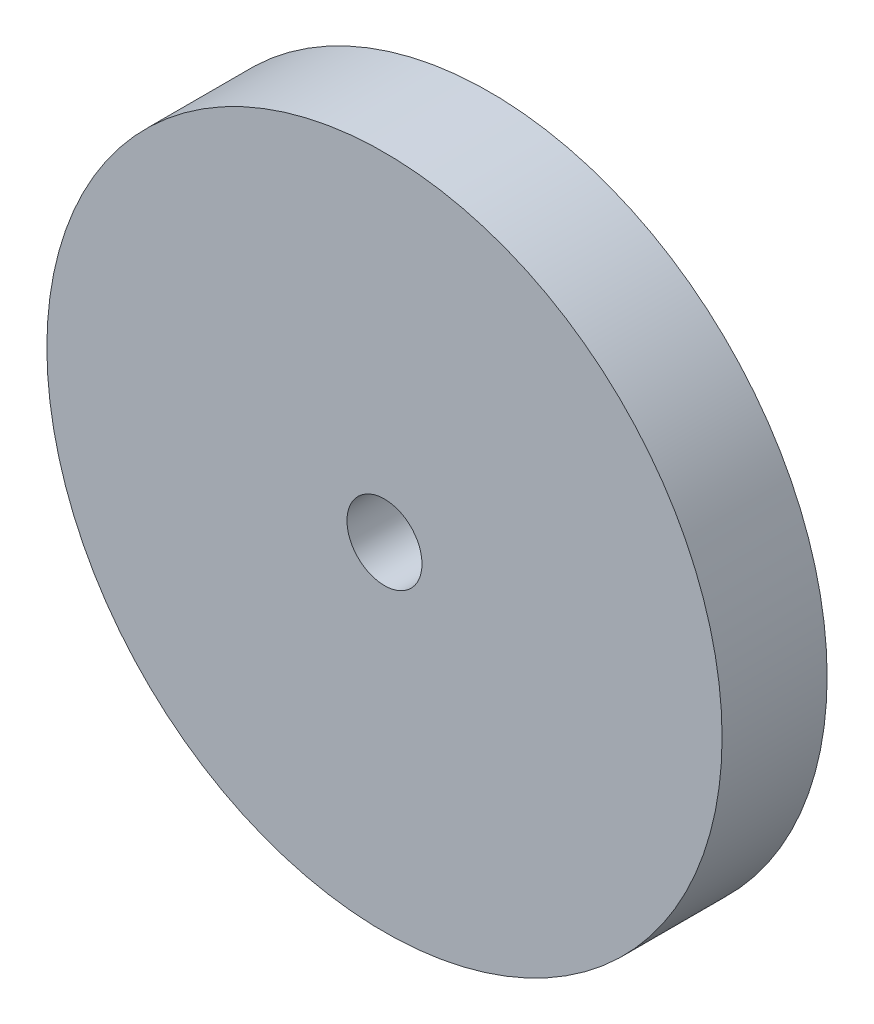
from build123d import *

# Parameters (mm, degrees)
SKETCH_1_R      = 9
SKETCH_1_R_2    = 1
EXTRUDE_1_DEPTH = 2.8


with BuildPart() as part:
    # 草圖1 → 填料-伸長1 (new body)
    with BuildSketch(Plane.XY):
        Circle(SKETCH_1_R)
        Circle(SKETCH_1_R_2, mode=Mode.SUBTRACT)
    extrude(amount=EXTRUDE_1_DEPTH)


solid = part.part
